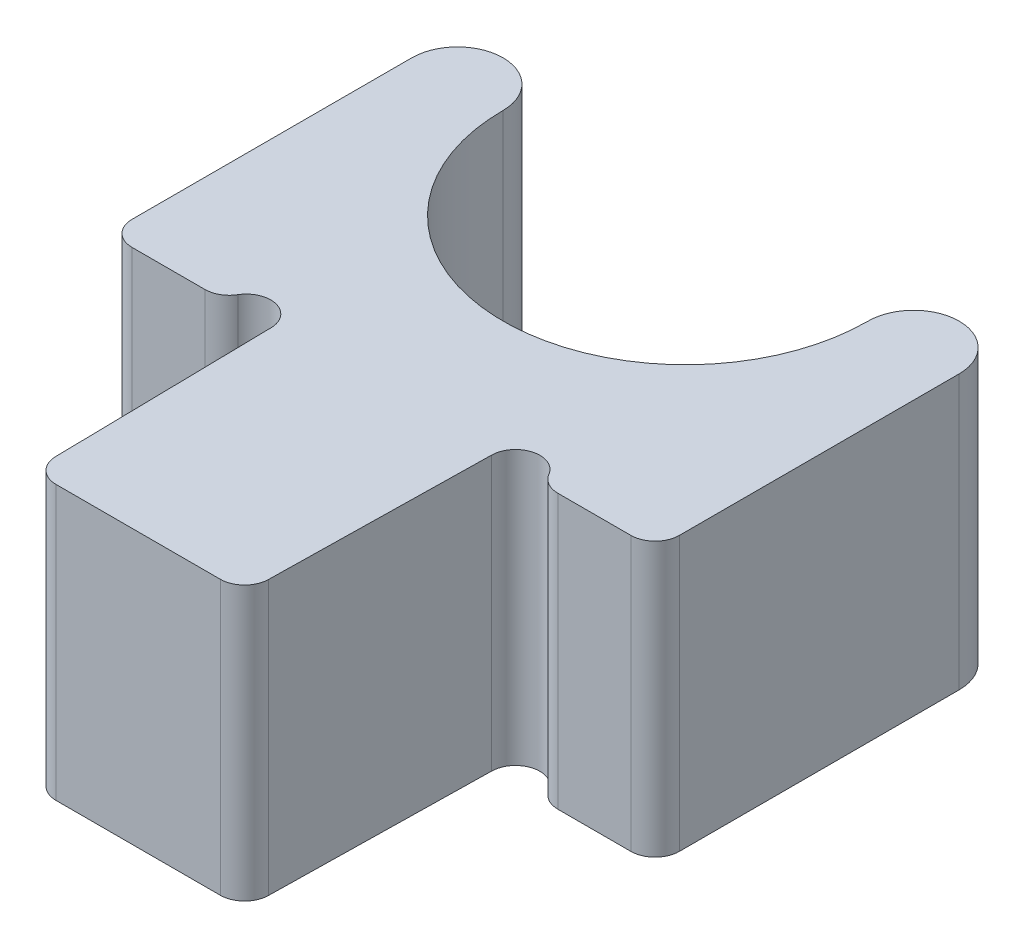
from build123d import *

# Parameters (mm, degrees)
BOSS_EXTRUDE1_DEPTH = 4.5


with BuildPart() as part:
    # Sketch1 → Boss-Extrude1 (new body)
    with BuildSketch(Plane(origin=(0, 0, 0), x_dir=(1, 0, 0), z_dir=(0, 1, 0))):
        with BuildLine():
            Line((-4.5, 0), (-4.5, -4.6))
            ThreePointArc((-4.5, -4.6), (-4.382842712, -4.882842712), (-4.1, -5))
            Line((-4.1, -5), (-2.901641857, -5))
            ThreePointArc((-2.901641857, -5), (-2.70339478, -4.947416315), (-2.557270511, -4.803490481))
            ThreePointArc((-2.557270511, -4.803490481), (-2.110791668, -4.620232906), (-1.812960087, -5))
            Line((-1.812960087, -5), (-1.75, -8.606980963))
            ThreePointArc((-1.75, -8.606980963), (-1.630424628, -8.88530018), (-1.350060922, -9))
            Line((-1.350060922, -9), (1.350060922, -9))
            ThreePointArc((1.350060922, -9), (1.630424628, -8.88530018), (1.75, -8.606980963))
            Line((1.75, -8.606980963), (1.812960087, -5))
            ThreePointArc((1.812960087, -5), (2.110791668, -4.620232906), (2.557270511, -4.803490481))
            ThreePointArc((2.557270511, -4.803490481), (2.70339478, -4.947416315), (2.901641857, -5))
            Line((2.901641857, -5), (4.1, -5))
            ThreePointArc((4.1, -5), (4.382842712, -4.882842712), (4.5, -4.6))
            Line((4.5, -4.6), (4.5, 0))
            ThreePointArc((4.5, 0), (3.75, 0.75), (3, 0))
            ThreePointArc((3, 0), (0, -3), (-3, 0))
            ThreePointArc((-3, 0), (-3.75, 0.75), (-4.5, 0))
        make_face()
    extrude(amount=BOSS_EXTRUDE1_DEPTH)


solid = part.part
